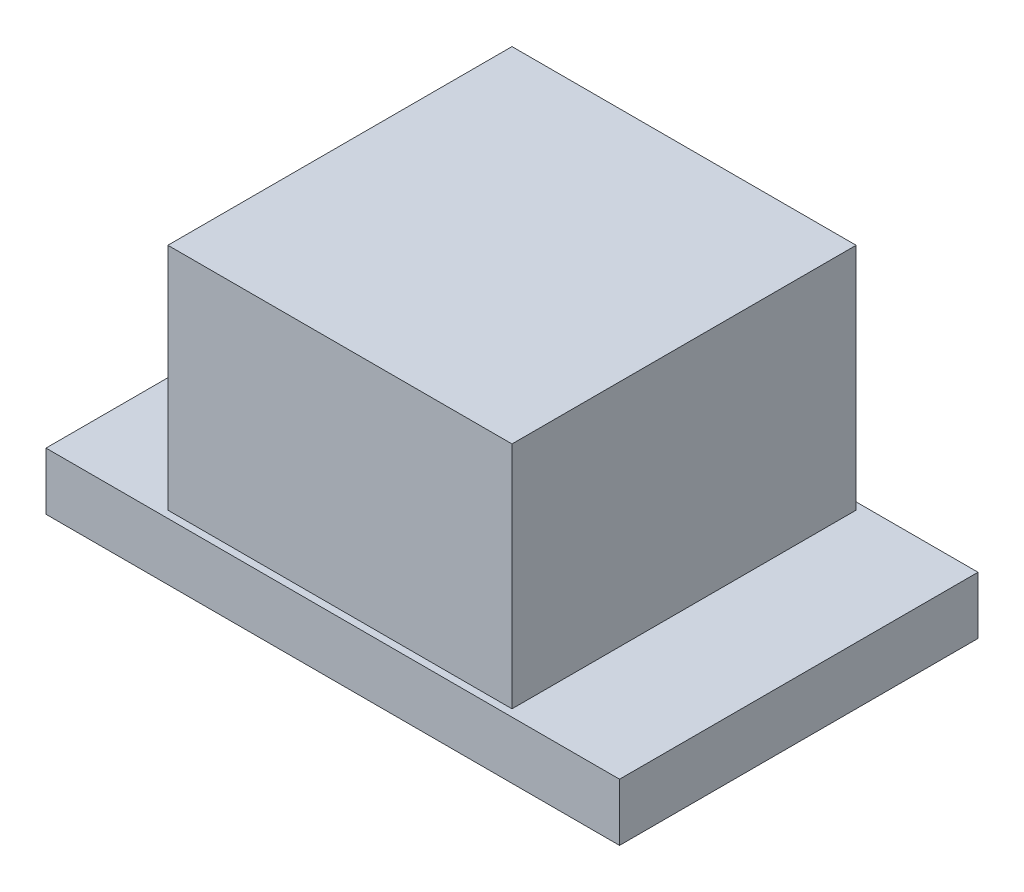
from build123d import *

# Parameters (mm, degrees)
SKETCH1_R           = 0.1
BOSS_EXTRUDE1_DEPTH = 0.3
SKETCH2_W           = 2
SKETCH2_H           = 1.25
BOSS_EXTRUDE2_DEPTH = 0.2
SKETCH3_W           = 1.2
SKETCH3_H           = 1.2
CUT_EXTRUDE1_DEPTH  = 0.01
SKETCH4_W           = 1.2
SKETCH4_H           = 1.2
BOSS_EXTRUDE4_DEPTH = 0.01
SKETCH5_W           = 1.2
SKETCH5_H           = 1.2
BOSS_EXTRUDE5_DEPTH = 0.8


with BuildPart() as part:
    # Sketch1 → Boss-Extrude1 (new body)
    with BuildSketch(Plane(origin=(0, 0, 0), x_dir=(1, 0, 0), z_dir=(0, 1, 0))):
        Circle(SKETCH1_R)
    extrude(amount=BOSS_EXTRUDE1_DEPTH)

    # Sketch2 → Boss-Extrude2 (add)
    with BuildSketch(Plane(origin=(0, 0, 0), x_dir=(1, 0, 0), z_dir=(0, 1, 0))):
        Rectangle(SKETCH2_W, SKETCH2_H)
    extrude(amount=BOSS_EXTRUDE2_DEPTH)

    # Sketch3 → Cut-Extrude1 (cut)
    with BuildSketch(Plane(origin=(0, 0.2, 0), x_dir=(1, 0, 0), z_dir=(0, 1, 0))):
        Rectangle(SKETCH3_W, SKETCH3_H)
    extrude(amount=-CUT_EXTRUDE1_DEPTH, mode=Mode.SUBTRACT)


with BuildPart() as body_2:
    # Sketch4 → Boss-Extrude4 (new body)
    with BuildSketch(Plane(origin=(0, 0.19, 0), x_dir=(1, 0, 0), z_dir=(0, 1, 0))):
        Rectangle(SKETCH4_W, SKETCH4_H)
    extrude(amount=BOSS_EXTRUDE4_DEPTH)


with BuildPart() as body_3:
    # Sketch5 → Boss-Extrude5 (new body)
    with BuildSketch(Plane(origin=(0, 0.2, 0), x_dir=(1, 0, 0), z_dir=(0, 1, 0))):
        Rectangle(SKETCH5_W, SKETCH5_H)
    extrude(amount=BOSS_EXTRUDE5_DEPTH)


solid = Compound([part.part, body_2.part, body_3.part])
